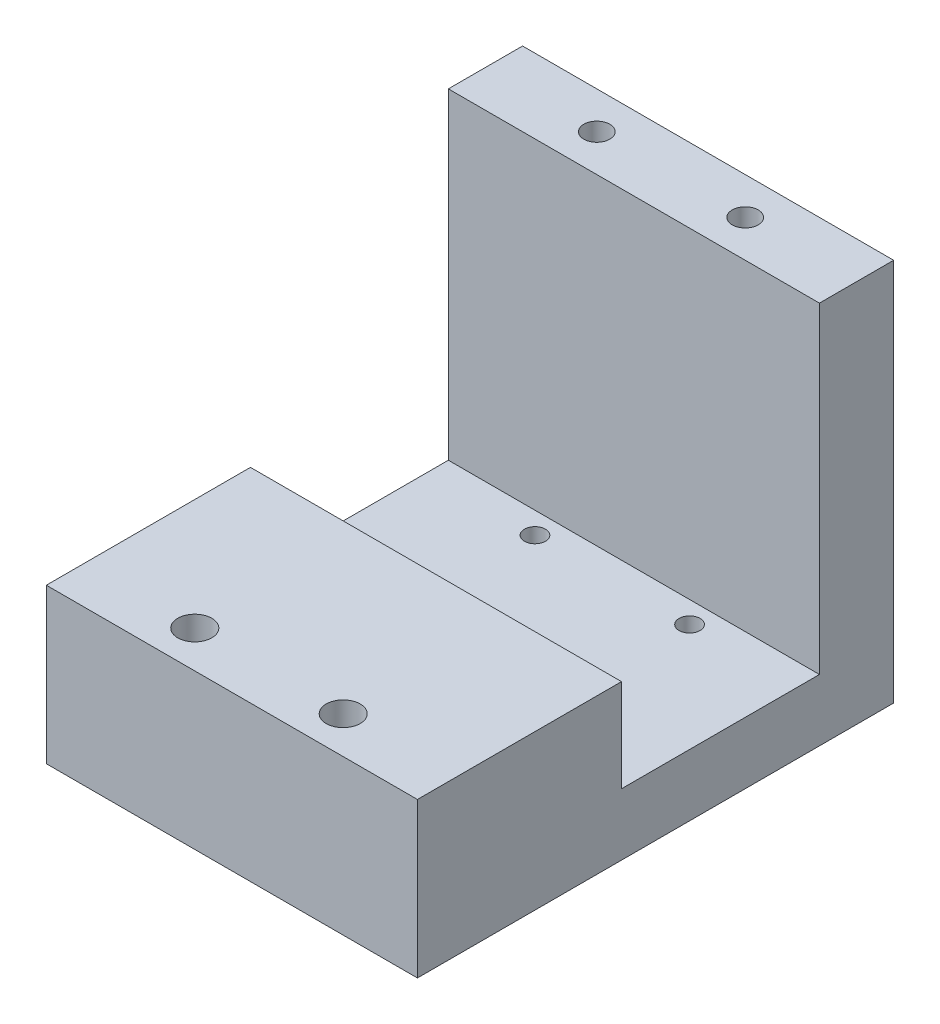
from build123d import *

# Parameters (mm, degrees)
SKETCH1_W                      = 60
SKETCH1_H                      = 77
BOSS_EXTRUDE1_DEPTH            = 10
SKETCH2_W                      = 60
SKETCH2_H                      = 12
BOSS_EXTRUDE2_DEPTH            = 52
SKETCH3_W                      = 60
SKETCH3_H                      = 33
BOSS_EXTRUDE3_DEPTH            = 15
M5X0_8_TAPPED_HOLE1_D          = 4.2
CBORE_FOR_M5_SHCS1_D           = 5.5
CBORE_FOR_M5_SHCS1_CBORE_D     = 10
CBORE_FOR_M5_SHCS1_CBORE_DEPTH = 20
CBORE_FOR_M3_SHCS1_D           = 3.4
CBORE_FOR_M3_SHCS1_CBORE_D     = 6.5
CBORE_FOR_M3_SHCS1_CBORE_DEPTH = 3


with BuildPart() as part:
    # Sketch1 → Boss-Extrude1 (new body)
    with BuildSketch(Plane(origin=(0, 0, 0), x_dir=(1, 0, 0), z_dir=(0, 1, 0))):
        with Locations((30, 38.5)):
            Rectangle(SKETCH1_W, SKETCH1_H)
    extrude(amount=BOSS_EXTRUDE1_DEPTH)

    # Sketch2 → Boss-Extrude2 (add)
    with BuildSketch(Plane(origin=(0, 10, 0), x_dir=(1, 0, 0), z_dir=(0, 1, 0))):
        with Locations((30, 71)):
            Rectangle(SKETCH2_W, SKETCH2_H)
    extrude(amount=BOSS_EXTRUDE2_DEPTH)

    # Sketch3 → Boss-Extrude3 (add)
    with BuildSketch(Plane(origin=(0, 10, 0), x_dir=(1, 0, 0), z_dir=(0, 1, 0))):
        with Locations((30, 16.5)):
            Rectangle(SKETCH3_W, SKETCH3_H)
    extrude(amount=BOSS_EXTRUDE3_DEPTH)

    # M5x0.8 Tapped Hole1 (through all)
    with Locations(Plane(origin=(0, 62, 0), x_dir=(1, 0, 0), z_dir=(0, 1, 0))):
        with Locations((18, 71), (42, 71)):
            Hole(M5X0_8_TAPPED_HOLE1_D / 2)

    # CBORE for M5 SHCS1 (through all)
    with Locations(Plane(origin=(0, 0, 0), x_dir=(-1, 0, 0), z_dir=(0, -1, 0))):
        with Locations((-42, 6), (-18, 6)):
            CounterBoreHole(CBORE_FOR_M5_SHCS1_D / 2, CBORE_FOR_M5_SHCS1_CBORE_D / 2, CBORE_FOR_M5_SHCS1_CBORE_DEPTH)

    # CBORE for M3 SHCS1 (through all)
    with Locations(Plane(origin=(0, 0, 0), x_dir=(-1, 0, 0), z_dir=(0, -1, 0))):
        with Locations((-42.5, 61.5), (-17.5, 61.5), (-17.5, 36.5), (-42.5, 36.5)):
            CounterBoreHole(CBORE_FOR_M3_SHCS1_D / 2, CBORE_FOR_M3_SHCS1_CBORE_D / 2, CBORE_FOR_M3_SHCS1_CBORE_DEPTH)


solid = part.part
